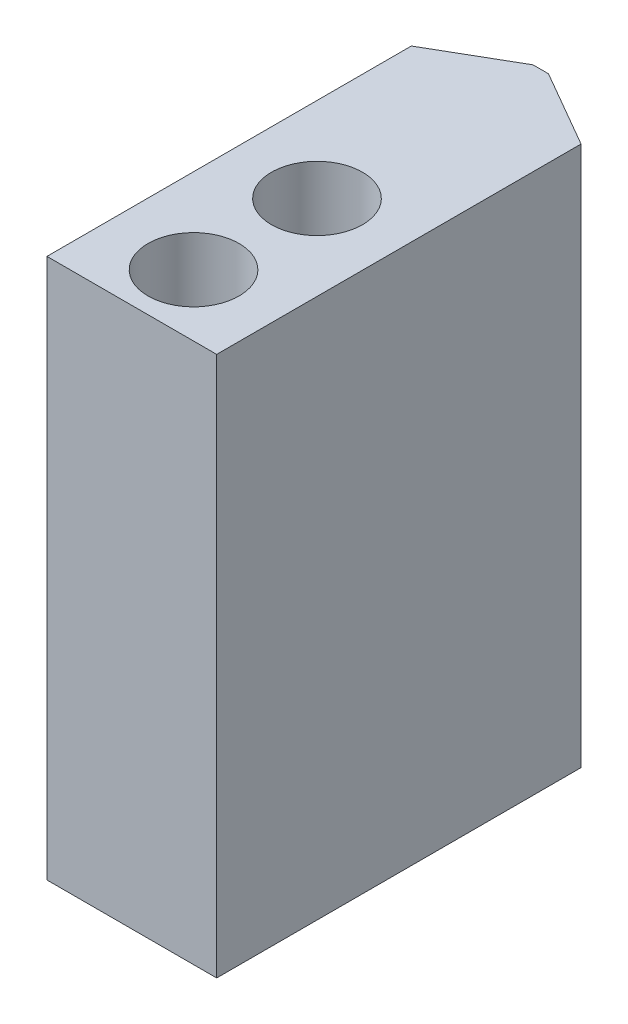
from build123d import *

# Parameters (mm, degrees)
BOSS_EXTRUDE1_DEPTH = 35


with BuildPart() as part:
    # Sketch1 → Boss-Extrude1 (new body)
    with BuildSketch(Plane(origin=(0, 0, 0), x_dir=(1, 0, 0), z_dir=(0, 1, 0))):
        Polygon((-5.5, -26.5), (5.5, -26.5), (5.5, -2.886751346), (0.5, 0), (-0.5, 0), (-5.5, -2.886751346), align=None)
    extrude(amount=BOSS_EXTRUDE1_DEPTH)

    # Sketch2 → Cut-Revolve1 (revolve, cut)
    with BuildSketch(Plane(origin=(0, 0, 0), x_dir=(0, 0, -1), z_dir=(1, 0, 0))):
        Polygon((-14.5, 35), (-11.55, 35), (-11.55, 6), (-12.9, 6), (-12.9, 1.3), (-12, 1.3), (-12, 0), (-14.5, 0), align=None)
    revolve(axis=Axis((0, 0, 14.5), (0, 1, 0)), mode=Mode.SUBTRACT)

    # Sketch3 → Cut-Revolve2 (revolve, cut)
    with BuildSketch(Plane(origin=(0, 0, 0), x_dir=(0, 0, -1), z_dir=(1, 0, 0))):
        Polygon((-22.5, 35), (-19.55, 35), (-19.55, 6), (-20.9, 6), (-20.9, 1.3), (-20, 1.3), (-20, 0), (-22.5, 0), align=None)
    revolve(axis=Axis((0, 0, 22.5), (0, 1, 0)), mode=Mode.SUBTRACT)


solid = part.part
